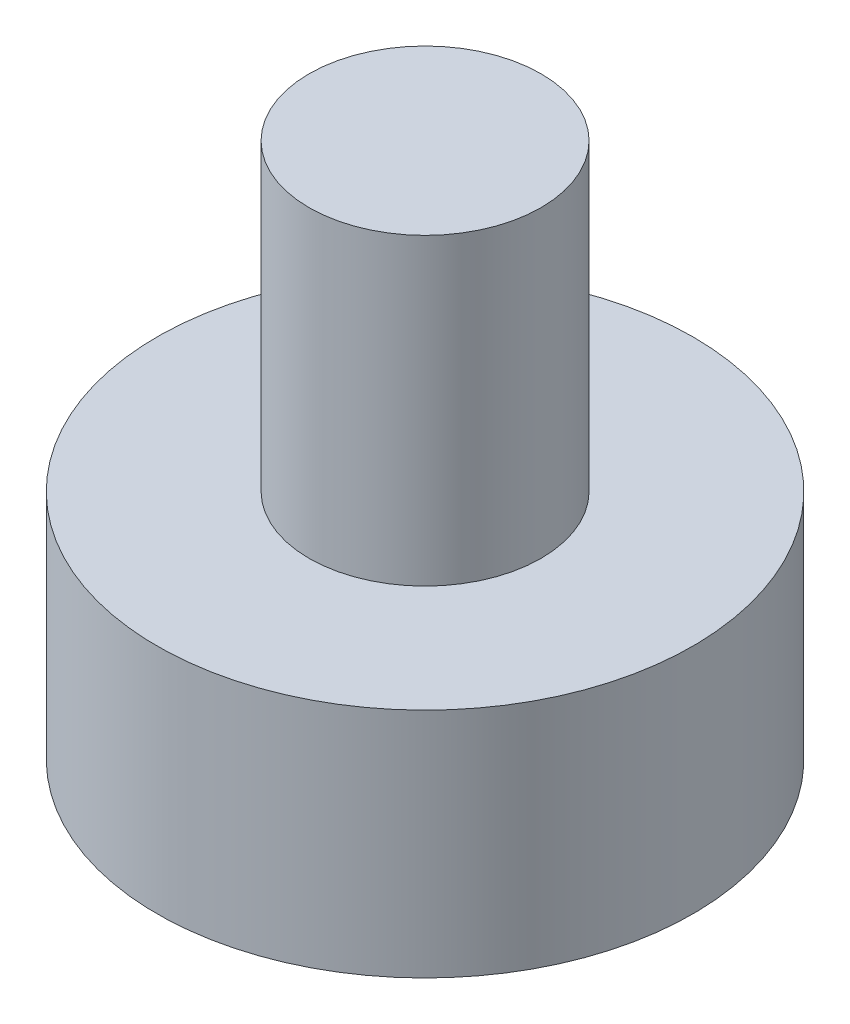
from build123d import *

# Parameters (mm, degrees)
SKETCH1_R           = 21
BOSS_EXTRUDE1_DEPTH = 55
SKETCH2_R           = 48.5
BOSS_EXTRUDE2_DEPTH = 42


with BuildPart() as part:
    # Sketch1 → Boss-Extrude1 (new body)
    with BuildSketch(Plane(origin=(0, 0, 0), x_dir=(1, 0, 0), z_dir=(0, 1, 0))):
        Circle(SKETCH1_R)
    extrude(amount=BOSS_EXTRUDE1_DEPTH)

    # Sketch2 → Boss-Extrude2 (add)
    with BuildSketch(Plane.XZ):
        Circle(SKETCH2_R)
    extrude(amount=BOSS_EXTRUDE2_DEPTH)


solid = part.part
